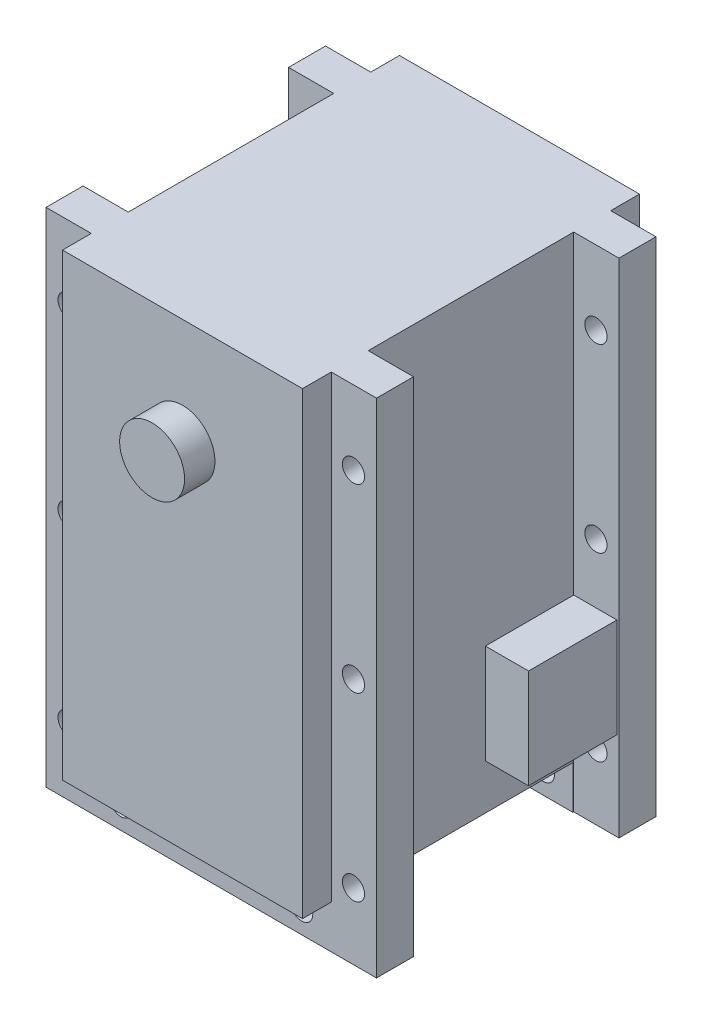
from build123d import *

# Parameters (mm, degrees)
SKETCH_2_W           = 40.2
SKETCH_2_H           = 61.1
EXTRUDE_1_DEPTH      = 20.5
SKETCH_9_W           = 24.8
SKETCH_9_H           = 5.25
SKETCH_9_W_2         = 3.5
CUT_EXTRUDE_3_DEPTH  = 41.2
SKETCH_10_W          = 5.5
SKETCH_10_H          = 25
SKETCH_10_H_2        = 3.5
CUT_EXTRUDE_4_DEPTH  = 62.1
SKETCH_12_R          = 1.35
CUT_EXTRUDE_5_DEPTH  = 42
SKETCH_13_R          = 3.95
EXTRUDE_2_DEPTH      = 3.7
SKETCH_14_R          = 3.95
EXTRUDE_4_DEPTH      = 1
SKETCH_16_W          = 10.75
SKETCH_16_H          = 12.1
EXTRUDE_6_DEPTH      = 5.25
EXTRUDE_6_DEPTH_BACK = 34.25


with BuildPart() as part:
    # 스케치2 → 보스-돌출1 (new body, symmetric)
    with BuildSketch(Plane.XY):
        with Locations((20.1, 30.55)):
            Rectangle(SKETCH_2_W, SKETCH_2_H)
    extrude(amount=EXTRUDE_1_DEPTH, both=True)

    # 스케치9 → 컷-돌출3 (cut, through all)
    with BuildSketch(Plane(origin=(40.2, 0, 0), x_dir=(0, 0, -1), z_dir=(1, 0, 0))):
        with Locations((0, 2.625)):
            Rectangle(SKETCH_9_W, SKETCH_9_H)
        with Locations((-18.75, 2.625)):
            Rectangle(SKETCH_9_W_2, SKETCH_9_H)
        with Locations((18.75, 2.625)):
            Rectangle(SKETCH_9_W_2, SKETCH_9_H)
    extrude(amount=-CUT_EXTRUDE_3_DEPTH, mode=Mode.SUBTRACT)

    # 스케치10 → 컷-돌출4 (cut, through all)
    with BuildSketch(Plane(origin=(0, 61.1, 0), x_dir=(1, 0, 0), z_dir=(0, 1, 0))):
        with Locations((2.75, 0)):
            Rectangle(SKETCH_10_W, SKETCH_10_H)
        with Locations((2.75, 18.75)):
            Rectangle(SKETCH_10_W, SKETCH_10_H_2)
        with Locations((37.45, 0)):
            Rectangle(SKETCH_10_W, SKETCH_10_H)
        with Locations((37.45, 18.75)):
            Rectangle(SKETCH_10_W, SKETCH_10_H_2)
        with Locations((2.75, -18.75)):
            Rectangle(SKETCH_10_W, SKETCH_10_H_2)
        with Locations((37.45, -18.75)):
            Rectangle(SKETCH_10_W, SKETCH_10_H_2)
    extrude(amount=-CUT_EXTRUDE_4_DEPTH, mode=Mode.SUBTRACT)

    # 스케치12 → 컷-돌출5 (cut, through all)
    with BuildSketch(Plane.XY.offset(20.5)):
        with Locations((9.1, 2.8)):
            Circle(SKETCH_12_R)
        with Locations((31.1, 2.8)):
            Circle(SKETCH_12_R)
        with Locations((2.8, 52.1)):
            Circle(SKETCH_12_R)
        with Locations((37.4, 52.1)):
            Circle(SKETCH_12_R)
        with Locations((2.8, 30.1)):
            Circle(SKETCH_12_R)
        with Locations((37.4, 30.1)):
            Circle(SKETCH_12_R)
        with Locations((2.8, 8.1)):
            Circle(SKETCH_12_R)
        with Locations((37.4, 8.1)):
            Circle(SKETCH_12_R)
    extrude(amount=-CUT_EXTRUDE_5_DEPTH, mode=Mode.SUBTRACT)

    # 스케치13 → 보스-돌출2 (add)
    with BuildSketch(Plane.XY.offset(20.5)):
        with Locations((20.1, 48.1)):
            Circle(SKETCH_13_R)
    extrude(amount=EXTRUDE_2_DEPTH)

    # 스케치14 → 보스-돌출4 (add)
    with BuildSketch(Plane(origin=(0, 0, -20.5), x_dir=(-1, 0, 0), z_dir=(0, 0, -1))):
        with Locations((-20.1, 48.1)):
            Circle(SKETCH_14_R)
    extrude(amount=EXTRUDE_4_DEPTH)

    # 스케치16 → 보스-돌출6 (add, two sides)
    with BuildSketch(Plane(origin=(34.7, 0, 0), x_dir=(0, 0, -1), z_dir=(1, 0, 0))) as extrude_6_sk:
        with Locations((7.125, 16.8)):
            Rectangle(SKETCH_16_W, SKETCH_16_H)
    extrude(amount=EXTRUDE_6_DEPTH)
    extrude(extrude_6_sk.sketch, amount=-EXTRUDE_6_DEPTH_BACK)


solid = part.part
